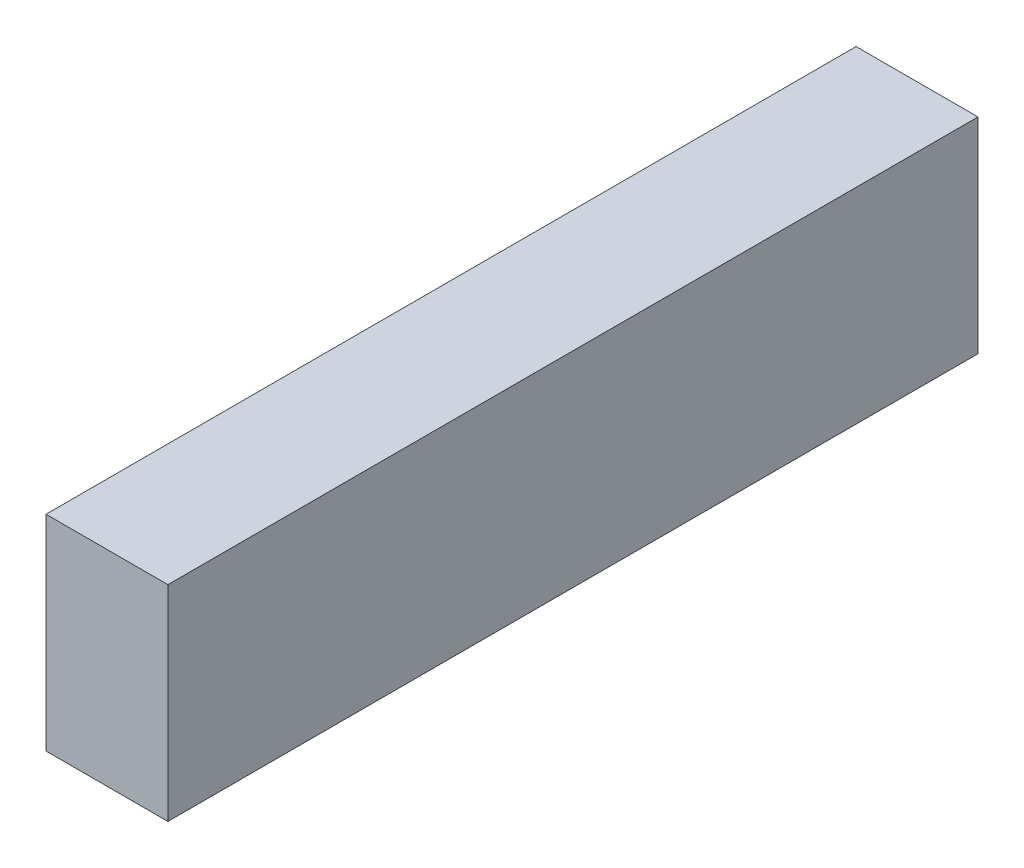
from build123d import *

# Parameters (mm, degrees)
SKETCH1_W           = 11.89
SKETCH1_H           = 20
BOSS_EXTRUDE1_DEPTH = 79
SKETCH4_R           = 2.15
CUT_EXTRUDE1_DEPTH  = 6.82
SKETCH5_R           = 2.15
CUT_EXTRUDE2_DEPTH  = 6.825


with BuildPart() as part:
    # Sketch1 → Boss-Extrude1 (new body)
    with BuildSketch(Plane.XY):
        with Locations((5.945, 10)):
            Rectangle(SKETCH1_W, SKETCH1_H)
    extrude(amount=BOSS_EXTRUDE1_DEPTH)

    # Sketch4 → Cut-Extrude1 (cut)
    with BuildSketch(Plane.ZY):
        with Locations((39.5, 10)):
            Circle(SKETCH4_R)
        with Locations((9.5, 10)):
            Circle(SKETCH4_R)
        with Locations((69.5, 10)):
            Circle(SKETCH4_R)
    extrude(amount=-CUT_EXTRUDE1_DEPTH, mode=Mode.SUBTRACT)

    # Sketch5 → Cut-Extrude2 (cut)
    with BuildSketch(Plane.XZ):
        with Locations((5.945, 39.5)):
            Circle(SKETCH5_R)
        with Locations((5.945, 69.5)):
            Circle(SKETCH5_R)
        with Locations((5.945, 9.5)):
            Circle(SKETCH5_R)
    extrude(amount=-CUT_EXTRUDE2_DEPTH, mode=Mode.SUBTRACT)


solid = part.part
